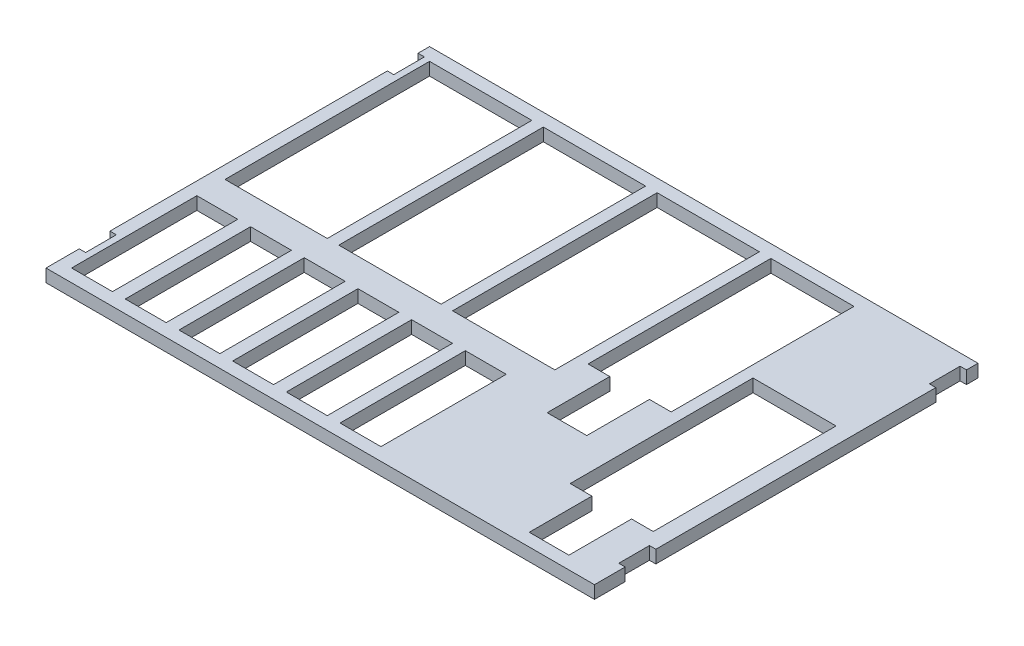
from build123d import *

# Parameters (mm, degrees)
SKETCH1_W           = 429
SKETCH1_H           = 300
BOSS_EXTRUDE1_DEPTH = 10
SKETCH2_W           = 80
SKETCH2_H           = 160
SKETCH2_W_2         = 32
SKETCH2_H_2         = 98
SKETCH2_W_3         = 5
SKETCH2_H_3         = 24
CUT_EXTRUDE1_DEPTH  = 10


with BuildPart() as part:
    # Sketch1 → Boss-Extrude1 (new body)
    with BuildSketch(Plane(origin=(0, 0, 0), x_dir=(1, 0, 0), z_dir=(0, 1, 0))):
        Rectangle(SKETCH1_W, SKETCH1_H)
    extrude(amount=-BOSS_EXTRUDE1_DEPTH)

    # Sketch2 → Cut-Extrude1 (cut)
    with BuildSketch(Plane(origin=(0, 0, 0), x_dir=(1, 0, 0), z_dir=(0, 1, 0))):
        with Locations((-164.5, 60)):
            Rectangle(SKETCH2_W, SKETCH2_H)
        with Locations((-75.5, 60)):
            Rectangle(SKETCH2_W, SKETCH2_H)
        with Locations((13.5, 60)):
            Rectangle(SKETCH2_W, SKETCH2_H)
        Polygon((127.5, 140), (62.5, 140), (62.5, -3), (79.5, -3), (79.5, -52), (110.5, -52), (110.5, -3), (127.5, -3), align=None)
        with Locations((-146.5, -91)):
            Rectangle(SKETCH2_W_2, SKETCH2_H_2)
        with Locations((-188.5, -91)):
            Rectangle(SKETCH2_W_2, SKETCH2_H_2)
        with Locations((-104.5, -91)):
            Rectangle(SKETCH2_W_2, SKETCH2_H_2)
        with Locations((-62.5, -91)):
            Rectangle(SKETCH2_W_2, SKETCH2_H_2)
        with Locations((-20.5, -91)):
            Rectangle(SKETCH2_W_2, SKETCH2_H_2)
        with Locations((21.5, -91)):
            Rectangle(SKETCH2_W_2, SKETCH2_H_2)
        Polygon((153.5, -140), (184.5, -140), (184.5, -91), (201.5, -91), (201.5, 52), (136.5, 52), (136.5, -91), (153.5, -91), align=None)
        with Locations((-212, 129)):
            Rectangle(SKETCH2_W_3, SKETCH2_H_3)
        with Locations((212, -114)):
            Rectangle(SKETCH2_W_3, SKETCH2_H_3)
        with Locations((212, 129)):
            Rectangle(SKETCH2_W_3, SKETCH2_H_3)
        with Locations((-212, -112)):
            Rectangle(SKETCH2_W_3, SKETCH2_H_3)
    extrude(amount=-CUT_EXTRUDE1_DEPTH, mode=Mode.SUBTRACT)


solid = part.part
